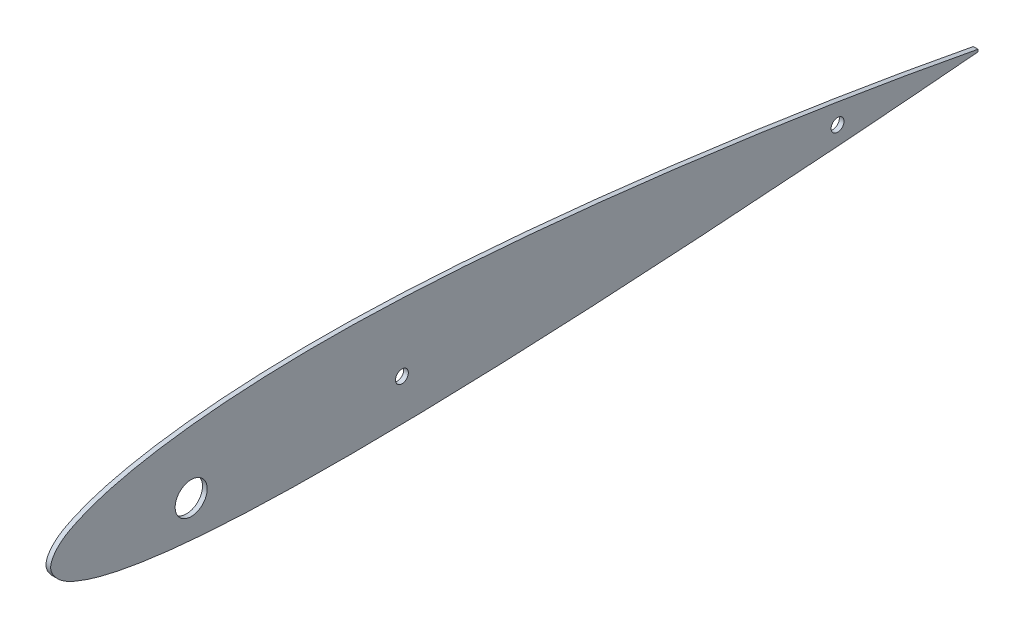
from build123d import *

# Parameters (mm, degrees)
AIRFOIL_RIB_DEPTH     = 2
SPAR_CUTS_R           = 6.83635542
SPAR_CUTS_R_2         = 2.75
SPAR_HOLES_DEPTH      = 3.0000001
SPAR_HOLES_DEPTH_BACK = 1.0000001


with BuildPart() as part:
    # airfoil → airfoil_rib (new body)
    with BuildSketch(Plane(origin=(0, 0, 0), x_dir=(0, 0, -1), z_dir=(1, 0, 0))):
        with BuildLine():
            Line((396.008399204, 0.498957664), (395.991600796, -0.498957664))
            add(Edge.make_bspline(
                [(396.008399204, 0.498957664), (389.462824097, 1.733249173), (376.36995532, 4.202156257), (350.130346293, 8.779005674), (317.273965613, 14.037010899), (277.764459592, 19.592966223), (238.194413225, 24.403739903), (198.563943314, 28.320876407), (158.827321429, 31.195227047), (125.619000864, 32.323419315), (99.007485828, 32.039525716), (79.044268017, 31.172926213), (59.083989094, 29.419963635), (42.486203803, 27.048187054), (29.257235646, 24.22756556), (19.298387332, 21.491222773), (10.923910447, 18.164714089), (3.74171629, 14.176349192), (-2.427972878, 6.586894807), (4.211907063, -0.563654636), (11.574259602, -4.123888705), (20.056102085, -6.965418644), (30.04790447, -9.195414118), (43.238969478, -11.419554546), (59.692327382, -13.228590325), (79.412867217, -14.522035765), (99.094288933, -15.201011306), (125.314305957, -15.524284639), (158.156003808, -15.157032144), (197.623979109, -13.883748685), (237.184466625, -11.955070821), (276.794221377, -9.581980095), (316.465196196, -6.89111675), (349.559664948, -4.400388659), (376.076140042, -2.241963807), (389.347649919, -1.080437919), (395.991600796, -0.498957664)],
                knots=[0, 0, 0, 0, 0.024758353, 0.049523206, 0.099002464, 0.148431641, 0.197816093, 0.247156978, 0.296440501, 0.345884085, 0.370605916, 0.395346156, 0.420138806, 0.445056029, 0.45762203, 0.470360867, 0.483523327, 0.490626325, 0.501772116, 0.512907947, 0.5199771, 0.533052484, 0.545674077, 0.558115541, 0.582725097, 0.607174358, 0.631557279, 0.655916257, 0.704636043, 0.753621853, 0.802687387, 0.851851698, 0.901113053, 0.950481472, 0.975210156, 1, 1, 1, 1], degree=3))
        make_face()
    extrude(amount=AIRFOIL_RIB_DEPTH)

    # spar_cuts → spar_holes (cut, two sides)
    with BuildSketch(Plane(origin=(0, 0, 0), x_dir=(0, 0, -1), z_dir=(1, 0, 0))) as spar_holes_sk:
        with Locations((60, 2.500001882)):
            Circle(SPAR_CUTS_R)
        with Locations((150, 2.500001882)):
            Circle(SPAR_CUTS_R_2)
        with Locations((336.033583383, 2.500001882)):
            Circle(SPAR_CUTS_R_2)
    extrude(amount=SPAR_HOLES_DEPTH, mode=Mode.SUBTRACT)
    extrude(spar_holes_sk.sketch, amount=-SPAR_HOLES_DEPTH_BACK, mode=Mode.SUBTRACT)


solid = part.part
